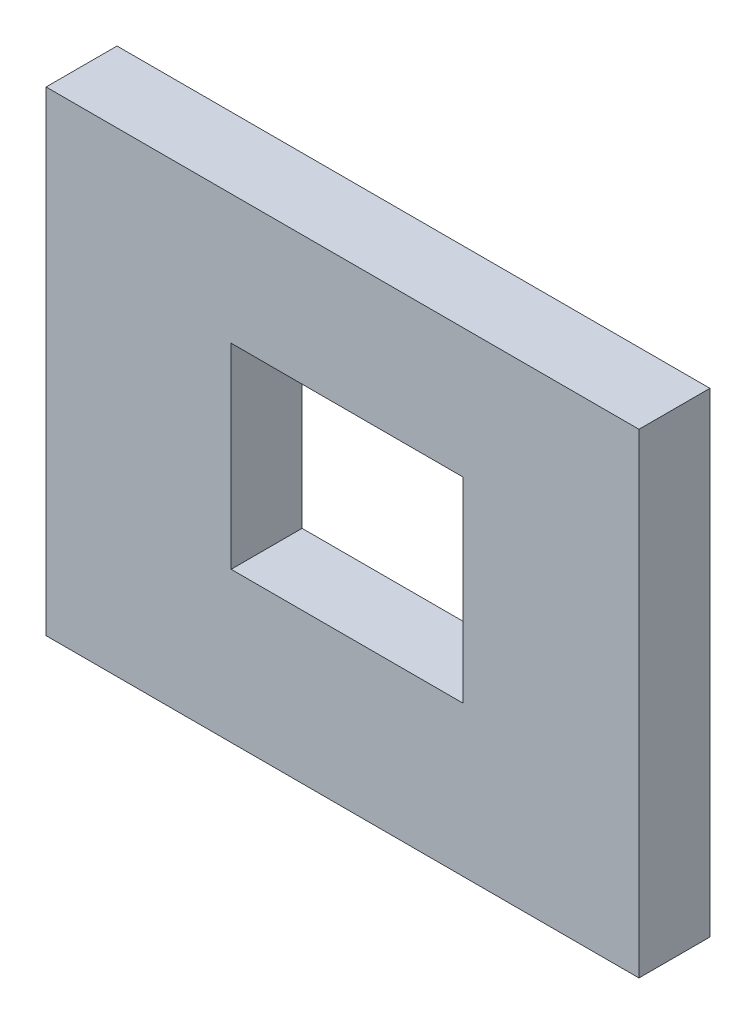
from build123d import *

# Parameters (mm, degrees)
SKIZZE1_W                       = 82.743246227
SKIZZE1_H                       = 66.319965537
SKIZZE1_W_2                     = 32.345087162
SKIZZE1_H_2                     = 27.330344966
AUFSATZ_LINEAR_AUSTRAGEN1_DEPTH = 9.9


with BuildPart() as part:
    # Skizze1 → Aufsatz-Linear austragen1 (new body)
    with BuildSketch(Plane.XY):
        with Locations((41.371623114, 33.159982769)):
            Rectangle(SKIZZE1_W, SKIZZE1_H)
        with Locations((41.998465888, 34.60172115)):
            Rectangle(SKIZZE1_W_2, SKIZZE1_H_2, mode=Mode.SUBTRACT)
    extrude(amount=-AUFSATZ_LINEAR_AUSTRAGEN1_DEPTH)


solid = part.part
